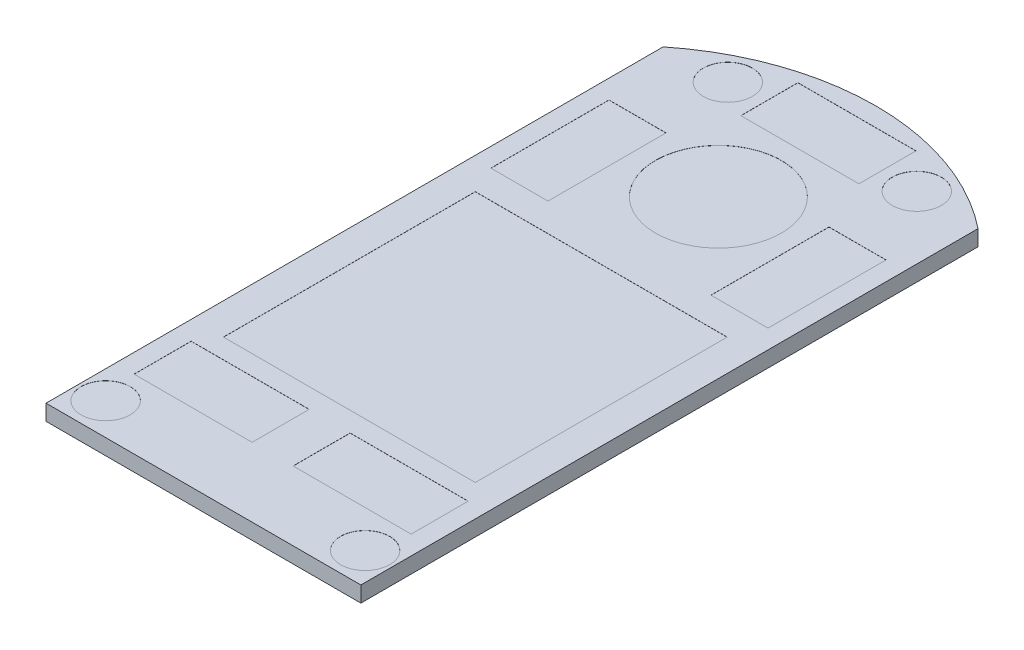
from build123d import *

# Parameters (mm, degrees)
BOSS_EXTRUDE1_DEPTH = 12.7
BOSS_EXTRUDE2_DEPTH = 11.43
BOSS_EXTRUDE3_DEPTH = 3.175
SKETCH25_W          = 101.6
SKETCH25_H          = 203.2
CUT_EXTRUDE16_DEPTH = 26.4
SKETCH31_W          = 40.64
SKETCH31_H          = 12.7
BOSS_EXTRUDE5_DEPTH = 3.175
SKETCH27_R          = 4.953
SKETCH27_R_2        = 12.7
SKETCH27_W          = 50.8
SKETCH27_H          = 50.8
CUT_EXTRUDE17_DEPTH = 0.0254
SKETCH28_W          = 23.8125
SKETCH28_H          = 11.509375
SKETCH28_W_2        = 11.509375
SKETCH28_H_2        = 23.8125
CUT_EXTRUDE18_DEPTH = 0.0254


with BuildPart() as part:
    # Sketch1 → Boss-Extrude1 (new body)
    with BuildSketch(Plane(origin=(0, 0, 0), x_dir=(1, 0, 0), z_dir=(0, 1, 0))):
        with BuildLine():
            Line((-31.75, 0), (31.75, 0))
            Line((31.75, 0), (31.75, 111.76))
            ThreePointArc((31.75, 111.76), (0, 122.90426271), (-31.75, 111.76))
            Line((-31.75, 111.76), (-31.75, 0))
        make_face()
    extrude(amount=BOSS_EXTRUDE1_DEPTH)

    # Sketch2 → Boss-Extrude2 (add)
    with BuildSketch(Plane.ZY.offset(31.75)):
        with BuildLine():
            Line((0, 0), (12.7, 0))
            ThreePointArc((12.7, 0), (21.680256121, 21.680256121), (0, 12.7))
            Line((0, 12.7), (0, 0))
        make_face()
    boss_extrude2 = extrude(amount=-BOSS_EXTRUDE2_DEPTH)

    # Mirror1: Boss-Extrude2 across plane
    add(boss_extrude2.mirror(Plane(origin=(0, 0, 0), x_dir=(0, 0, 1), z_dir=(1, 0, 0))))

    # Sketch24 → Boss-Extrude3 (add)
    with BuildSketch(Plane.XZ):
        with BuildLine():
            Line((20.32, 0), (-20.32, 0))
            Line((-20.32, 0), (-20.32, 12.7))
            Line((-20.32, 12.7), (-31.75, 12.7))
            Line((-31.75, 12.7), (-31.75, -111.76))
            ThreePointArc((-31.75, -111.76), (0, -122.90426271), (31.75, -111.76))
            Line((31.75, -111.76), (31.75, 12.7))
            Line((31.75, 12.7), (20.32, 12.7))
            Line((20.32, 12.7), (20.32, 0))
        make_face()
    extrude(amount=BOSS_EXTRUDE3_DEPTH)

    # Sketch25 → Cut-Extrude16 (cut, through all)
    with BuildSketch(Plane(origin=(0, 0, 0), x_dir=(-1, 0, 0), z_dir=(0, -1, 0))):
        with Locations((12.008205385, 70.319547201)):
            Rectangle(SKETCH25_W, SKETCH25_H)
    extrude(amount=-CUT_EXTRUDE16_DEPTH, mode=Mode.SUBTRACT)

    # Sketch31 → Boss-Extrude5 (add)
    with BuildSketch(Plane(origin=(0, 0, 0), x_dir=(1, 0, 0), z_dir=(0, 1, 0))):
        with Locations((0, -6.35)):
            Rectangle(SKETCH31_W, SKETCH31_H)
    extrude(amount=-BOSS_EXTRUDE5_DEPTH)

    # Sketch27 → Cut-Extrude17 (cut)
    with BuildSketch(Plane(origin=(0, 0, 0), x_dir=(1, 0, 0), z_dir=(0, 1, 0))):
        with Locations((19.05, 112.10926271)):
            Circle(SKETCH27_R)
        with Locations((-19.05, 112.10926271)):
            Circle(SKETCH27_R)
        with Locations((26.162, -6.25473729)):
            Circle(SKETCH27_R)
        with Locations((-26.162, -6.25473729)):
            Circle(SKETCH27_R)
        with Locations((0, 91.15426271)):
            Circle(SKETCH27_R_2)
        with Locations((0, 42.13226271)):
            Rectangle(SKETCH27_W, SKETCH27_H)
    extrude(amount=-CUT_EXTRUDE17_DEPTH, mode=Mode.SUBTRACT)

    # Sketch28 → Cut-Extrude18 (cut)
    with BuildSketch(Plane(origin=(0, 0, 0), x_dir=(1, 0, 0), z_dir=(0, 1, 0))):
        with Locations((-16.03375, 7.0088125)):
            Rectangle(SKETCH28_W, SKETCH28_H)
        with Locations((22.1853125, 85.12175)):
            Rectangle(SKETCH28_W_2, SKETCH28_H_2)
        with Locations((16.03375, 7.0088125)):
            Rectangle(SKETCH28_W, SKETCH28_H)
        with Locations((0, 113.33957521)):
            Rectangle(SKETCH28_W, SKETCH28_H)
        with Locations((-22.1853125, 85.12175)):
            Rectangle(SKETCH28_W_2, SKETCH28_H_2)
    extrude(amount=-CUT_EXTRUDE18_DEPTH, mode=Mode.SUBTRACT)


solid = part.part
